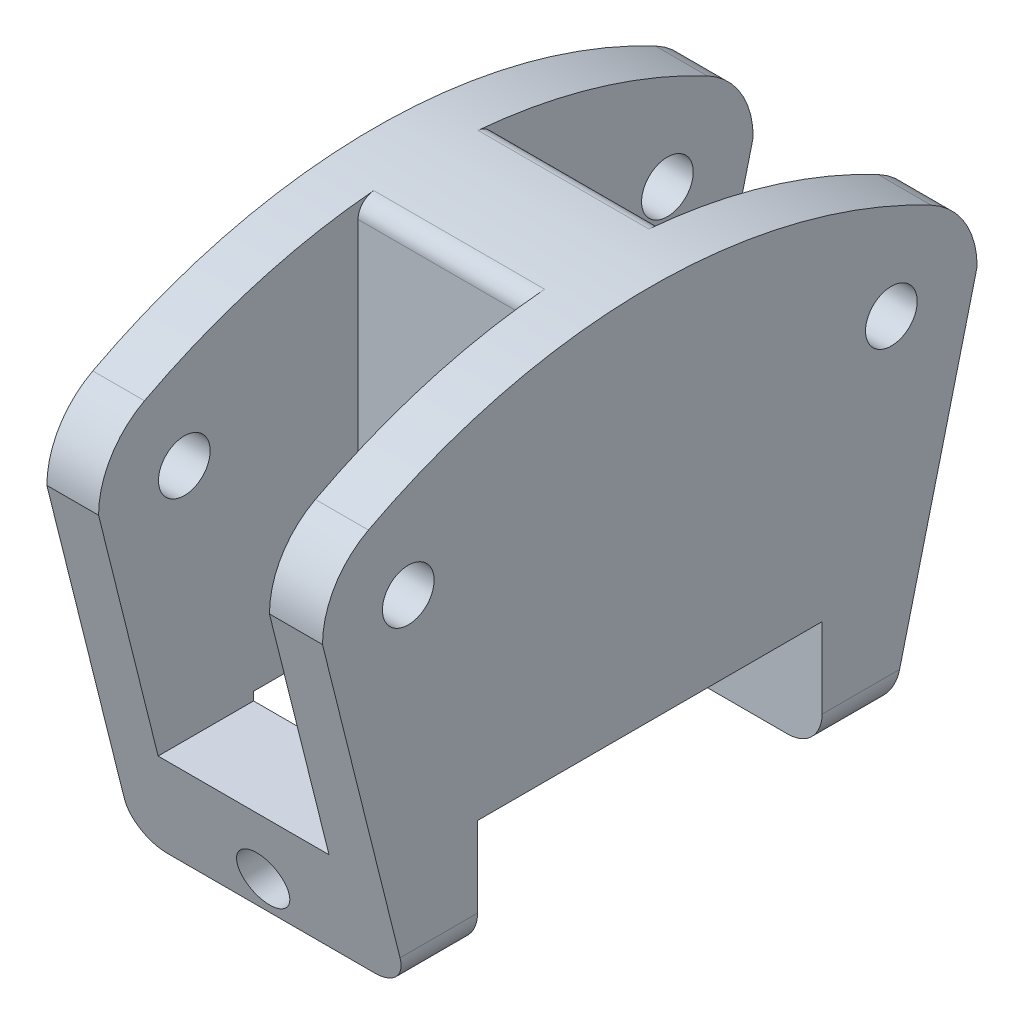
from build123d import *

# Parameters (mm, degrees)
BOSS_EXTRUDE1_DEPTH = 16
SKETCH4_W           = 20
SKETCH4_H           = 6.652028381
CUT_EXTRUDE1_DEPTH  = 17
SKETCH5_R           = 1.5
CUT_EXTRUDE2_DEPTH  = 17
SKETCH6_W           = 9.919414232
SKETCH6_H           = 19.005976718
CUT_EXTRUDE3_DEPTH  = 23
FILLET3_R           = 2
FILLET6_R           = 1
SKETCH7_R           = 1.5
CUT_EXTRUDE4_DEPTH  = 40.7726311
FILLET7_R           = 2


with BuildPart() as part:
    # Sketch3 → Boss-Extrude1 (new body)
    with BuildSketch(Plane(origin=(0, 0, 0), x_dir=(0, 0, -1), z_dir=(1, 0, 0))):
        with BuildLine():
            Line((-14, 0), (14, 0))
            Line((14, 0), (19, 20))
            ThreePointArc((19, 20), (18.281744193, 22.581988897), (16.333333333, 24.422166387))
            ThreePointArc((16.333333333, 24.422166387), (0, 28.467001677), (-16.333333333, 24.422166387))
            ThreePointArc((-16.333333333, 24.422166387), (-18.281744193, 22.581988897), (-19, 20))
            Line((-19, 20), (-14, 0))
        make_face()
    extrude(amount=BOSS_EXTRUDE1_DEPTH)

    # Sketch4 → Cut-Extrude1 (cut, through all)
    with BuildSketch(Plane(origin=(16, 0, 0), x_dir=(0, 0, -1), z_dir=(1, 0, 0))):
        with Locations((0, 3.326014191)):
            Rectangle(SKETCH4_W, SKETCH4_H)
    extrude(amount=-CUT_EXTRUDE1_DEPTH, mode=Mode.SUBTRACT)

    # Sketch5 → Cut-Extrude2 (cut, through all)
    with BuildSketch(Plane.ZY):
        with Locations((-14.02107691, 20)):
            Circle(SKETCH5_R)
    cut_extrude2 = extrude(amount=-CUT_EXTRUDE2_DEPTH, mode=Mode.SUBTRACT)

    # Mirror3: Cut-Extrude2 across plane
    add(cut_extrude2.mirror(Plane.XY), mode=Mode.SUBTRACT)

    # Sketch6 → Cut-Extrude3 (cut)
    with BuildSketch(Plane(origin=(0, 29.164714895, 0), x_dir=(1, 0, 0), z_dir=(0, 1, 0))):
        with Locations((7.960322343, 13.441432697)):
            Rectangle(SKETCH6_W, SKETCH6_H)
    cut_extrude3 = extrude(amount=-CUT_EXTRUDE3_DEPTH, mode=Mode.SUBTRACT)

    # Mirror4: Cut-Extrude3 across plane
    add(cut_extrude3.mirror(Plane.XY), mode=Mode.SUBTRACT)

    # Fillet3
    fillet3_edges = [part.edges().sort_by_distance(p)[0] for p in [
        (7.960322343, 6.652028381, -3.938444338),
        (7.960322343, 6.652028381, 3.938444338),
    ]]
    fillet(fillet3_edges, radius=FILLET3_R)

    # Fillet6
    fillet6_edges = [part.edges().sort_by_distance(p)[0] for p in [
        (7.960322343, 28.244705112, -3.938444338),
        (7.960322343, 28.244705112, 3.938444338),
    ]]
    fillet(fillet6_edges, radius=FILLET6_R)

    # Sketch7 → Cut-Extrude4 (cut, through all)
    with BuildSketch(Plane.XY.offset(20.7726311)):
        with Locations((8.056637232, 2)):
            Circle(SKETCH7_R)
    extrude(amount=-CUT_EXTRUDE4_DEPTH, mode=Mode.SUBTRACT)

    # Fillet7
    fillet7_edges = [part.edges().sort_by_distance(p)[0] for p in [
        (0, 0, -12),
        (16, 0, -12),
        (16, 0, 12),
        (0, 0, 12),
    ]]
    fillet(fillet7_edges, radius=FILLET7_R)


solid = part.part
